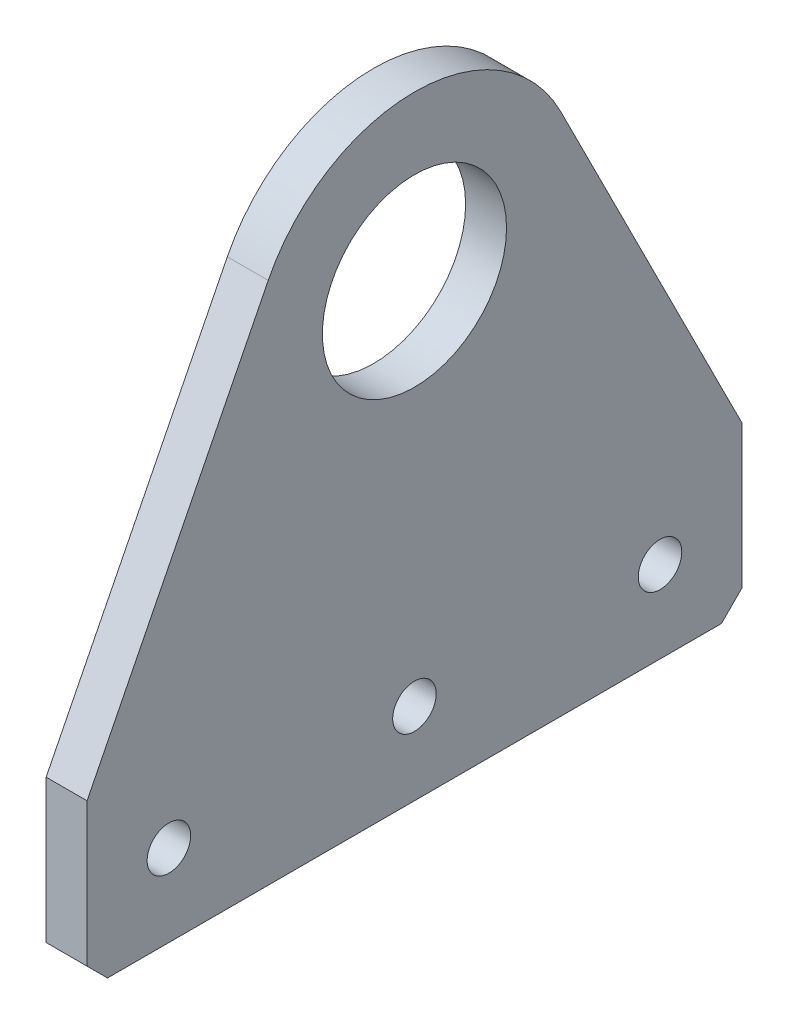
from build123d import *

# Parameters (mm, degrees)
SKETCH1_R           = 14.2875
BOSS_EXTRUDE1_DEPTH = 6.35
SKETCH2_R           = 3.3782
CUT_EXTRUDE1_DEPTH  = 7.35
CHAMFER1_SIZE       = 3.175


with BuildPart() as part:
    # Sketch1 → Boss-Extrude1 (new body)
    with BuildSketch(Plane(origin=(0, 0, 0), x_dir=(0, 0, -1), z_dir=(1, 0, 0))):
        with BuildLine():
            Line((0, 0), (0, 25.4))
            Line((0, 25.4), (28.110381264, 81.266707127))
            ThreePointArc((28.110381264, 81.266707127), (50.8, 95.25), (73.489618736, 81.266707127))
            Line((73.489618736, 81.266707127), (101.6, 25.4))
            Line((101.6, 25.4), (101.6, 0))
            Line((101.6, 0), (0, 0))
        make_face()
        with Locations((50.8, 69.85)):
            Circle(SKETCH1_R, mode=Mode.SUBTRACT)
    extrude(amount=BOSS_EXTRUDE1_DEPTH)

    # Sketch2 → Cut-Extrude1 (cut, through all)
    with BuildSketch(Plane(origin=(6.35, 0, 0), x_dir=(0, 0, -1), z_dir=(1, 0, 0))):
        with Locations((12.7, 12.7)):
            Circle(SKETCH2_R)
        with Locations((50.8, 12.7)):
            Circle(SKETCH2_R)
        with Locations((88.9, 12.7)):
            Circle(SKETCH2_R)
    extrude(amount=-CUT_EXTRUDE1_DEPTH, mode=Mode.SUBTRACT)

    # Chamfer1
    chamfer1_edges = [part.edges().sort_by_distance(p)[0] for p in [
        (3.175, 0, 0),
        (3.175, 0, -101.6),
    ]]
    chamfer(chamfer1_edges, length=CHAMFER1_SIZE)


solid = part.part
